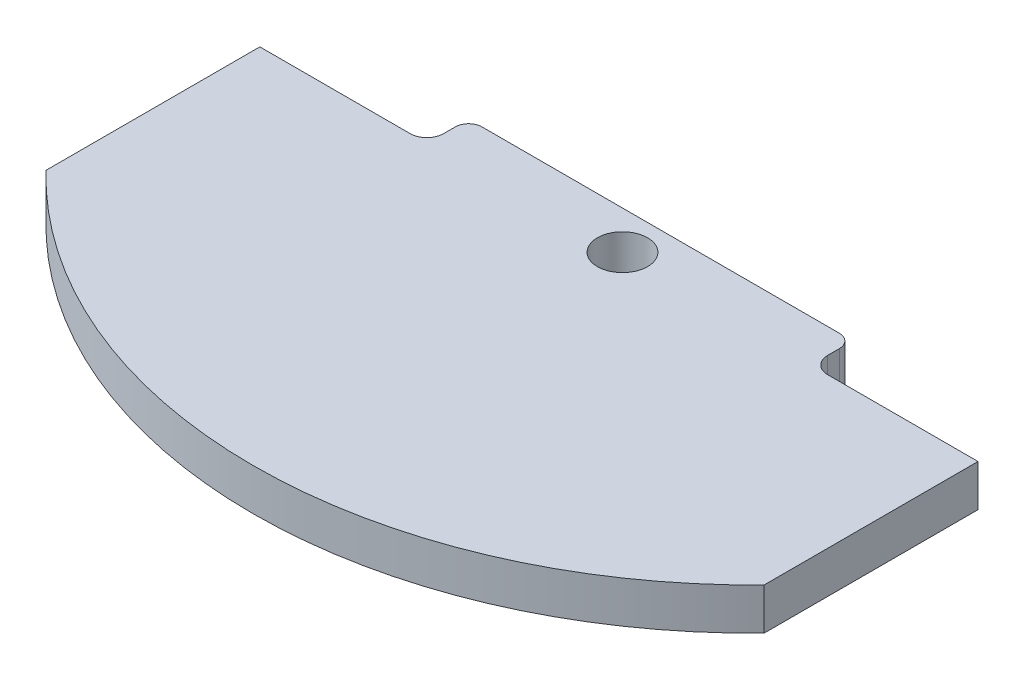
from build123d import *

# Parameters (mm, degrees)
BOSS_EXTRUDE2_DEPTH = 6.35
SKETCH10_W          = 25.4
SKETCH10_H          = 6.35
CUT_EXTRUDE1_DEPTH  = 7.35
FILLET1_R           = 2.54
FILLET2_R           = 2.032
SKETCH11_R          = 3.81
CUT_EXTRUDE2_DEPTH  = 7.35


with BuildPart() as part:
    # Sketch6 → Boss-Extrude2 (new body)
    with BuildSketch(Plane(origin=(0, 0, 0), x_dir=(1, 0, 0), z_dir=(0, 1, 0))):
        with BuildLine():
            Line((0, 0), (109.1946, 0))
            Line((109.1946, 0), (109.1946, -38.862))
            ThreePointArc((109.1946, -38.862), (54.5973, -61.992965275), (0, -38.862))
            Line((0, -38.862), (0, 0))
        make_face()
    extrude(amount=BOSS_EXTRUDE2_DEPTH)

    # Sketch10 → Cut-Extrude1 (cut, through all)
    with BuildSketch(Plane(origin=(0, 6.35, 0), x_dir=(1, 0, 0), z_dir=(0, 1, 0))):
        with Locations((96.4946, -3.175)):
            Rectangle(SKETCH10_W, SKETCH10_H)
        with Locations((12.7, -3.175)):
            Rectangle(SKETCH10_W, SKETCH10_H)
    extrude(amount=-CUT_EXTRUDE1_DEPTH, mode=Mode.SUBTRACT)

    # Fillet1
    fillet1_edges = [part.edges().sort_by_distance(p)[0] for p in [
        (25.4, 3.175, 6.35),
        (83.7946, 3.175, 6.35),
    ]]
    fillet(fillet1_edges, radius=FILLET1_R)

    # Fillet2
    fillet2_edges = [part.edges().sort_by_distance(p)[0] for p in [
        (25.4, 3.175, 0),
        (83.7946, 3.175, 0),
    ]]
    fillet(fillet2_edges, radius=FILLET2_R)

    # Sketch11 → Cut-Extrude2 (cut, through all)
    with BuildSketch(Plane.XZ):
        with Locations((54.61, 5.819375203)):
            Circle(SKETCH11_R)
    extrude(amount=-CUT_EXTRUDE2_DEPTH, mode=Mode.SUBTRACT)


solid = part.part
